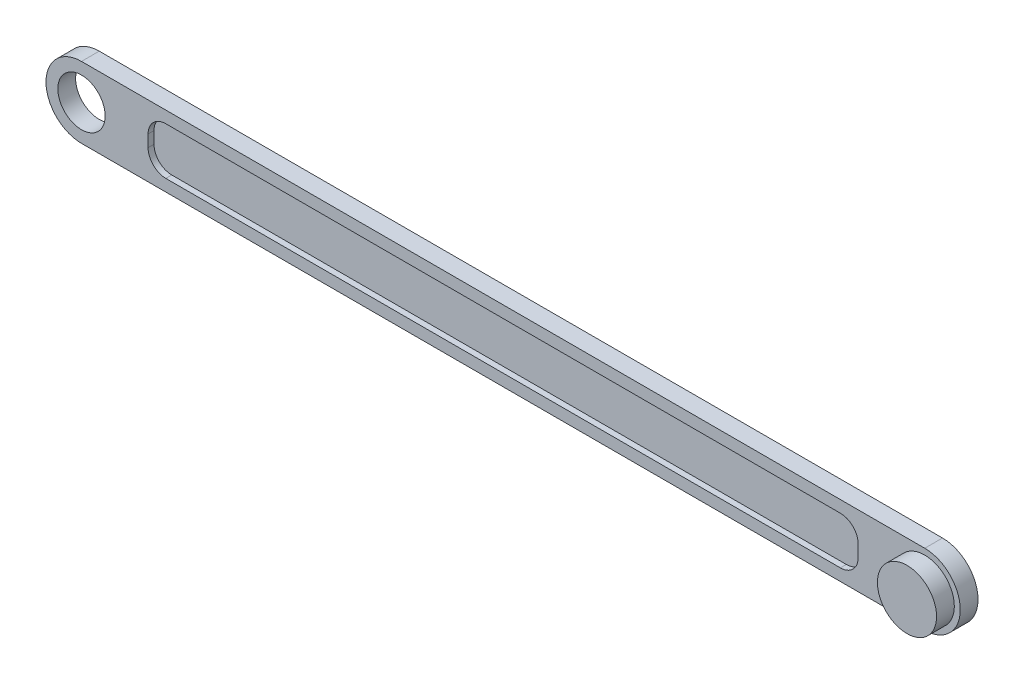
from build123d import *

# Parameters (mm, degrees)
SKETCH1_R           = 4
BOSS_EXTRUDE1_DEPTH = 3
SKETCH3_R           = 5
BOSS_EXTRUDE2_DEPTH = 3
SKETCH4_W           = 120
SKETCH4_H           = 8
CUT_EXTRUDE1_DEPTH  = 1
FILLET1_R           = 3


with BuildPart() as part:
    # Sketch1 → Boss-Extrude1 (new body)
    with BuildSketch(Plane.XY):
        with BuildLine():
            Line((0, 6), (142.5, 6))
            ThreePointArc((142.5, 6), (148.5, 0), (142.5, -6))
            Line((142.5, -6), (0, -6))
            ThreePointArc((0, -6), (-6, 0), (0, 6))
        make_face()
        Circle(SKETCH1_R, mode=Mode.SUBTRACT)
        with Locations((142.5, 0)):
            Circle(SKETCH1_R, mode=Mode.SUBTRACT)
    extrude(amount=BOSS_EXTRUDE1_DEPTH)

    # Sketch3 → Boss-Extrude2 (add)
    with BuildSketch(Plane.XY.offset(3)):
        with Locations((142.5, 0)):
            Circle(SKETCH3_R)
    extrude(amount=BOSS_EXTRUDE2_DEPTH)

    # Sketch4 → Cut-Extrude1 (cut)
    with BuildSketch(Plane.XY.offset(3)):
        with Locations((71.25, 0)):
            Rectangle(SKETCH4_W, SKETCH4_H)
    extrude(amount=-CUT_EXTRUDE1_DEPTH, mode=Mode.SUBTRACT)

    # Fillet1
    fillet1_edges = [part.edges().sort_by_distance(p)[0] for p in [
        (131.25, 4, 2.5),
        (131.25, -4, 2.5),
        (11.25, -4, 2.5),
        (11.25, 4, 2.5),
    ]]
    fillet(fillet1_edges, radius=FILLET1_R)


solid = part.part
